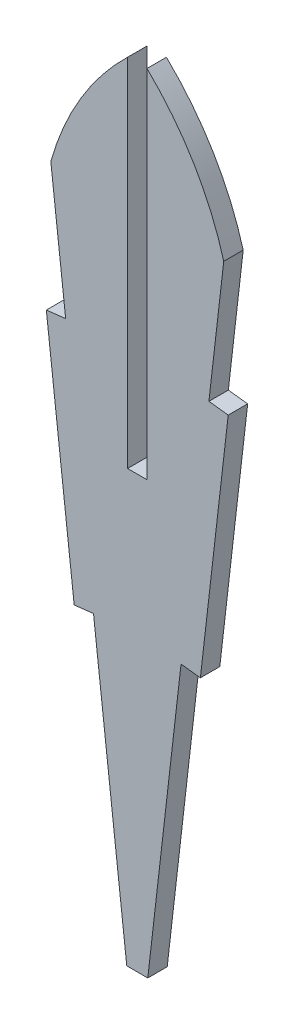
from build123d import *

# Parameters (mm, degrees)
BOSS_EXTRUDE1_DEPTH = 1.524


with BuildPart() as part:
    # Sketch1 → Boss-Extrude1 (new body)
    with BuildSketch(Plane.XY):
        with BuildLine():
            Line((0, -185.062075144), (-1.524, -185.062075144))
            Line((-1.524, -185.062075144), (-1.524, -157.15233073))
            ThreePointArc((-1.524, -157.15233073), (-5.202982181, -161.792523258), (-7.537553978, -167.234588225))
            Line((-7.537553978, -167.234588225), (-6.374749179, -177.316845721))
            Line((-6.374749179, -177.316845721), (-7.888713502, -177.491453935))
            Line((-7.888713502, -177.491453935), (-5.70611082, -196.416007973))
            Line((-5.70611082, -196.416007973), (-4.192146497, -196.241399759))
            Line((-4.192146497, -196.241399759), (-1.585117021, -218.846004156))
            Line((-1.585117021, -218.846004156), (0.061117021, -218.846004156))
            Line((0.061117021, -218.846004156), (2.668146497, -196.241399759))
            Line((2.668146497, -196.241399759), (4.18211082, -196.416007973))
            Line((4.18211082, -196.416007973), (6.364713502, -177.491453935))
            Line((6.364713502, -177.491453935), (4.850749179, -177.316845721))
            Line((4.850749179, -177.316845721), (6.013553978, -167.234588225))
            ThreePointArc((6.013553978, -167.234588225), (3.678982181, -161.792523258), (0, -157.15233073))
            Line((0, -157.15233073), (0, -185.062075144))
        make_face()
    extrude(amount=BOSS_EXTRUDE1_DEPTH)


solid = part.part
